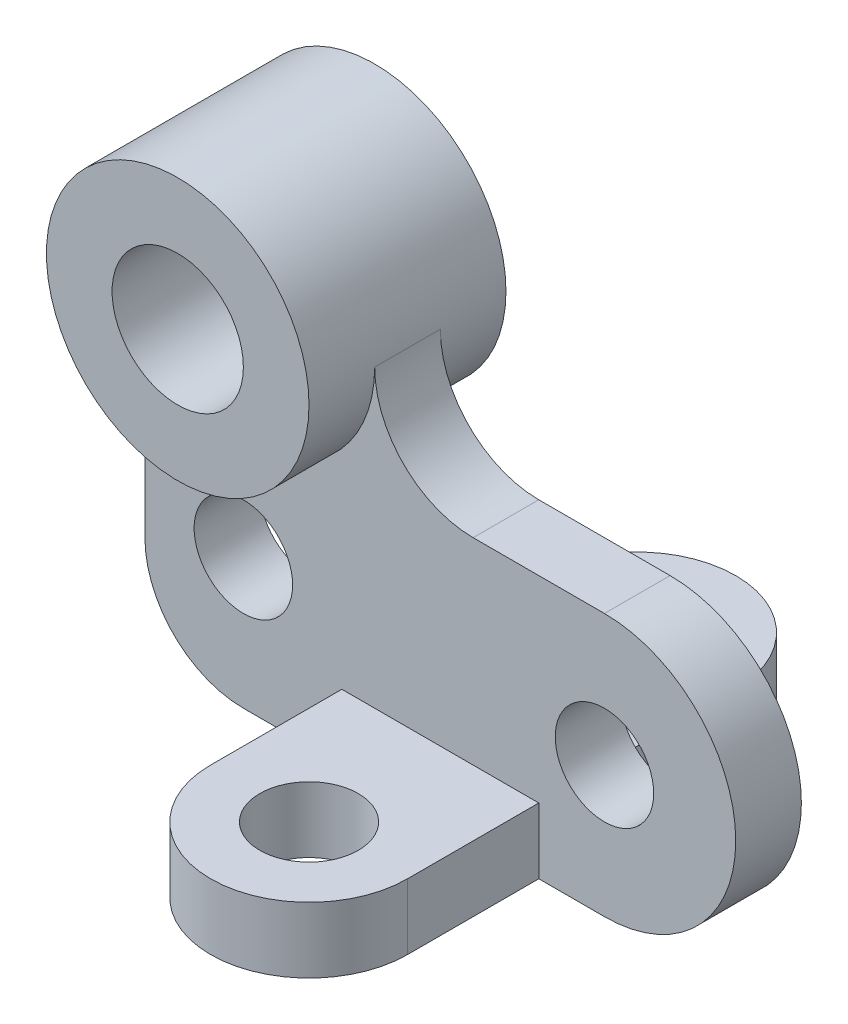
from build123d import *

# Parameters (mm, degrees)
SKETCH2_R           = 9.524999999999999
SKETCH2_R_2         = 9.524999999999993
BOSS_EXTRUDE1_DEPTH = 6.35
SKETCH2_3_R         = 12.7
BOSS_EXTRUDE2_DEPTH = 19.05
SKETCH3_R           = 9.525
BOSS_EXTRUDE3_DEPTH = 12.7


with BuildPart() as part:
    # Sketch2 → Boss-Extrude1 (new, symmetric)
    with BuildSketch(Plane.XY):
        with BuildLine():
            ThreePointArc((25.4, -6.22e-15), (8.980256121069143, -23.75952440601453), (-19.05000000000001, -16.80052082526014))
            Line((-19.050000000000008, -16.80052082526014), (-19.050000000000004, -50.799999999999855))
            ThreePointArc((-19.050000000000004, -50.79999999999986), (-13.470384181603738, -64.27038418160373), (1.3351e-13, -69.85))
            Line((1.3531e-13, -69.85), (69.85, -69.85))
            ThreePointArc((69.84999999999998, -69.85), (95.25, -44.45), (69.85, -19.05))
            Line((69.85, -19.049999999999997), (44.45, -19.049999999999997))
            ThreePointArc((44.45, -19.05), (30.979615818396276, -13.470384181603727), (25.4, 3.1e-16))
        make_face()
        with Locations((0, -44.449999999999996)):
            Circle(SKETCH2_R, mode=Mode.SUBTRACT)
        with Locations((69.85, -44.449999999999996)):
            Circle(SKETCH2_R_2, mode=Mode.SUBTRACT)
    extrude(amount=BOSS_EXTRUDE1_DEPTH, both=True)

    # Sketch2_3 → Boss-Extrude2 (add, symmetric)
    with BuildSketch(Plane.XY):
        with BuildLine():
            ThreePointArc((25.4, 0), (-8.980256121069145, 23.759524406014528), (-19.05000000000001, -16.80052082526014))
            ThreePointArc((-19.05000000000001, -16.80052082526014), (8.980256121069143, -23.75952440601453), (25.4, -6.22e-15))
        make_face()
        Circle(SKETCH2_3_R, mode=Mode.SUBTRACT)
    extrude(amount=BOSS_EXTRUDE2_DEPTH, both=True)

    # Sketch3 → Boss-Extrude3 (add)
    with BuildSketch(Plane.XZ.offset(69.85)):
        with BuildLine():
            Line((19.050000000000008, -31.75), (19.050000000000008, 31.75))
            ThreePointArc((19.050000000000008, 31.75), (38.10000000000001, 50.79999999999998), (57.14999999999999, 31.75))
            Line((57.14999999999999, 31.75), (57.14999999999999, -31.75))
            ThreePointArc((57.14999999999999, -31.75), (38.10000000000001, -50.8), (19.050000000000008, -31.75))
        make_face()
        with Locations((38.10000000000001, 31.75)):
            Circle(SKETCH3_R, mode=Mode.SUBTRACT)
        with Locations((38.10000000000001, -31.75)):
            Circle(SKETCH3_R, mode=Mode.SUBTRACT)
    extrude(amount=-BOSS_EXTRUDE3_DEPTH)


solid = part.part
